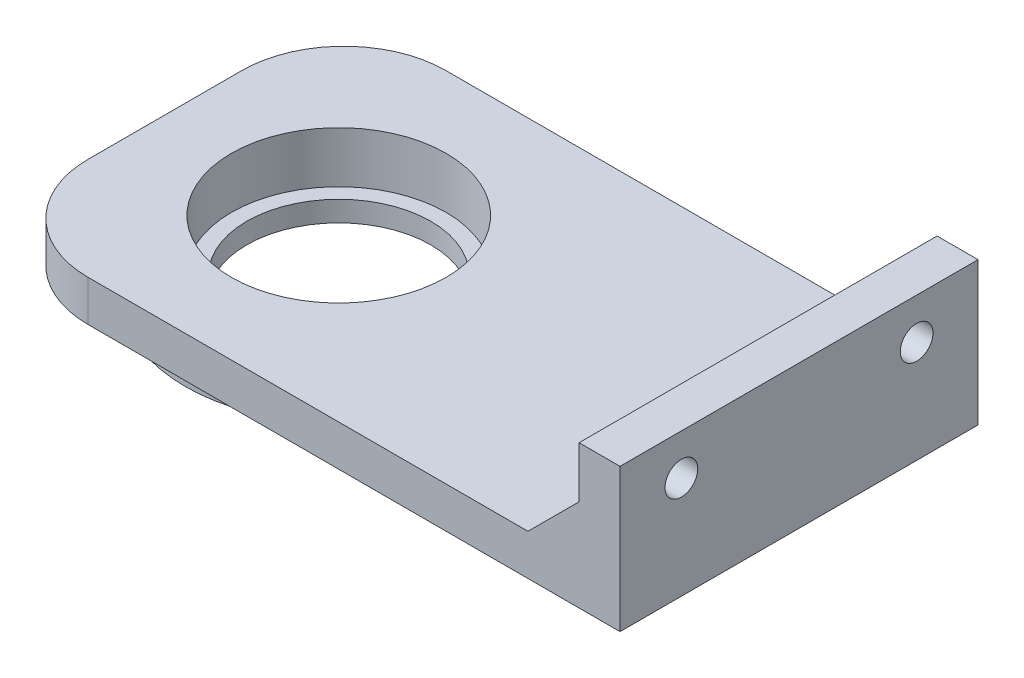
from build123d import *

# Parameters (mm, degrees)
SKETCH_1_W           = 62
SKETCH_1_H           = 35
SKETCH_1_R           = 10.5
EXTRUDE_1_DEPTH      = 4
SKETCH_3_R           = 15
SKETCH_3_R_2         = 10.5
EXTRUDE_2_DEPTH      = 5
EXTRUDE_2_DEPTH_BACK = 1
FILLET_1_R           = 10
SKETCH_4_W           = 4
SKETCH_4_H           = 35
EXTRUDE_3_DEPTH      = 10
CHAMFER_1_SIZE       = 5
SKETCH_5_R           = 1.6
CUT_EXTRUDE_1_DEPTH  = 25
SKETCH_6_R           = 3
CUT_EXTRUDE_2_DEPTH  = 25
SKETCH_7_W           = 33.228870124
SKETCH_7_H           = 2.665820387
CUT_EXTRUDE_3_DEPTH  = 50
SKETCH_8_R           = 15
SKETCH_8_R_2         = 9
EXTRUDE_4_DEPTH      = 2


with BuildPart() as part:
    # Эскиз1 → Бобышка-Вытянуть1 (new body)
    with BuildSketch(Plane(origin=(0, 0, 0), x_dir=(1, 0, 0), z_dir=(0, 1, 0))):
        Rectangle(SKETCH_1_W, SKETCH_1_H)
        with Locations((-14, 0)):
            Circle(SKETCH_1_R, mode=Mode.SUBTRACT)
    extrude(amount=EXTRUDE_1_DEPTH)

    # Эскиз3 → Бобышка-Вытянуть2 (add, two sides)
    with BuildSketch(Plane(origin=(0, 0, 0), x_dir=(1, 0, 0), z_dir=(0, 1, 0))) as extrude_2_sk:
        with Locations((-14, 0)):
            Circle(SKETCH_3_R)
        with Locations((-14, 0)):
            Circle(SKETCH_3_R_2, mode=Mode.SUBTRACT)
    extrude(amount=EXTRUDE_2_DEPTH)
    extrude(extrude_2_sk.sketch, amount=-EXTRUDE_2_DEPTH_BACK)

    # Скругление1
    fillet_1_edges = [part.edges().sort_by_distance(p)[0] for p in [
        (-31, 2, -17.5),
        (-31, 2, 17.5),
    ]]
    fillet(fillet_1_edges, radius=FILLET_1_R)

    # Эскиз4 → Бобышка-Вытянуть3 (add)
    with BuildSketch(Plane(origin=(0, 4, 0), x_dir=(1, 0, 0), z_dir=(0, 1, 0))):
        with Locations((29, 0)):
            Rectangle(SKETCH_4_W, SKETCH_4_H)
    extrude(amount=EXTRUDE_3_DEPTH)

    # Фаска1
    chamfer_1_edges = [part.edges().sort_by_distance(p)[0] for p in [
        (27, 4, 0),
    ]]
    chamfer(chamfer_1_edges, length=CHAMFER_1_SIZE)

    # Эскиз5 → Вырез-Вытянуть1 (cut)
    with BuildSketch(Plane(origin=(31, 0, 0), x_dir=(0, 0, -1), z_dir=(1, 0, 0))):
        with Locations((-11.5, 10)):
            Circle(SKETCH_5_R)
        with Locations((11.5, 10)):
            Circle(SKETCH_5_R)
    extrude(amount=-CUT_EXTRUDE_1_DEPTH, mode=Mode.SUBTRACT)

    # Эскиз6 → Вырез-Вытянуть2 (cut)
    with BuildSketch(Plane.ZY.offset(-27)):
        with Locations((-11.5, 10)):
            Circle(SKETCH_6_R)
        with Locations((11.5, 10)):
            Circle(SKETCH_6_R)
    extrude(amount=CUT_EXTRUDE_2_DEPTH, mode=Mode.SUBTRACT)

    # Эскиз7 → Вырез-Вытянуть3 (cut)
    with BuildSketch(Plane.XY.offset(17.5)):
        with Locations((-14.385564938, 5.332910194)):
            Rectangle(SKETCH_7_W, SKETCH_7_H)
    extrude(amount=-CUT_EXTRUDE_3_DEPTH, mode=Mode.SUBTRACT)

    # Эскиз8 → Бобышка-Вытянуть4 (add)
    with BuildSketch(Plane.XZ.offset(1)):
        with Locations((-14, 0)):
            Circle(SKETCH_8_R)
        with Locations((-14, 0)):
            Circle(SKETCH_8_R_2, mode=Mode.SUBTRACT)
    extrude(amount=EXTRUDE_4_DEPTH)


solid = part.part
